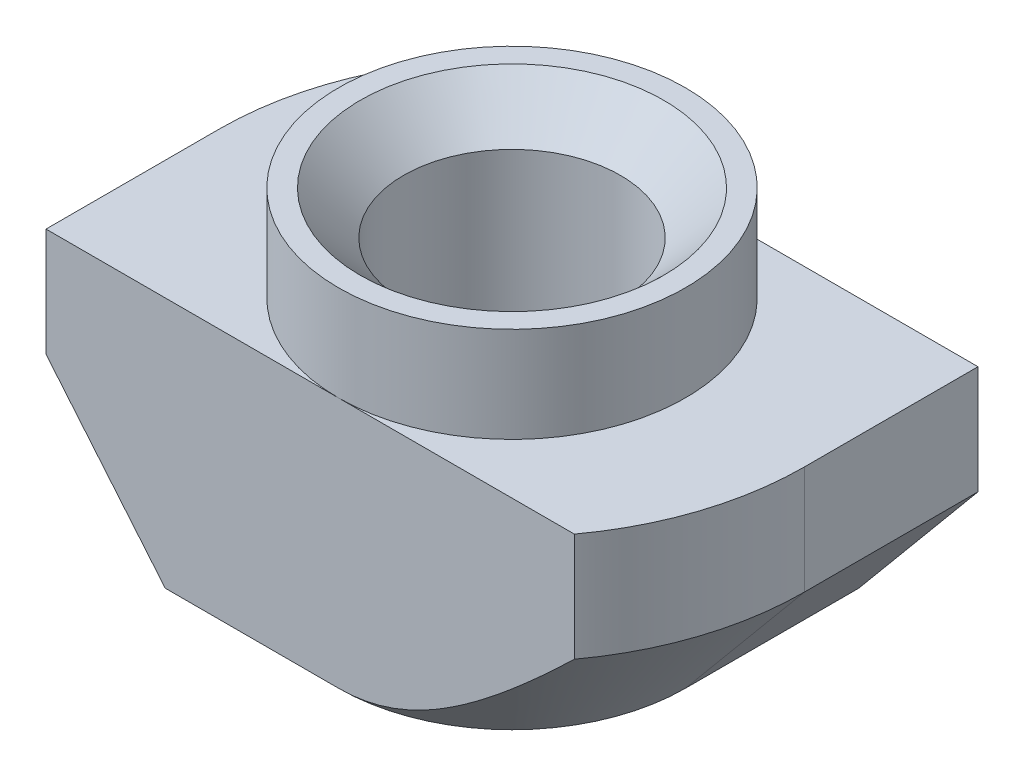
from build123d import *

# Parameters (mm, degrees)
EXTRUDE_1_DEPTH     = 4
SKETCH_4_OUTSIDE_W  = 19.022
SKETCH_4_OUTSIDE_H  = 13.522
SKETCH_4_OUTSIDE_R  = 4
CUT_EXTRUDE_1_DEPTH = 2.2
CUT_EXTRUDE_2_DEPTH = 6.8


with BuildPart() as part:
    # Эскиз1 → Бобышка-Вытянуть1 (new body, symmetric)
    with BuildSketch(Plane.XY):
        Polygon((4, 0), (-4, 0), (-4, -2.2), (-6.75, -2.2), (-6.75, -8), (6.75, -8), (6.75, -2.2), (4, -2.2), align=None)
    extrude(amount=EXTRUDE_1_DEPTH, both=True)

    # Эскиз3 → Отверстие обработанное метчиком M62 (revolve, cut)
    with BuildSketch(Plane(origin=(0, 0, 0), x_dir=(0, 0, 1), z_dir=(1, 0, 0))):
        Polygon((0, 0), (0, 8), (3.5, 8), (2.5, 7), (2.5, 1), (3.5, 0), align=None)
    revolve(axis=Axis((0, 6.35, 0), (0, -1, 0)), mode=Mode.SUBTRACT)

    # Эскиз4 outside → Вырез-Вытянуть1 (cut)
    with BuildSketch(Plane(origin=(0, 0, 0), x_dir=(1, 0, 0), z_dir=(0, 1, 0))):
        Rectangle(SKETCH_4_OUTSIDE_W, SKETCH_4_OUTSIDE_H)
        with Locations(Location((0, 0, 0), (0, 0, 270))):  # turned: the seam where the file's is
            Circle(SKETCH_4_OUTSIDE_R, mode=Mode.SUBTRACT)
    extrude(amount=-CUT_EXTRUDE_1_DEPTH, mode=Mode.SUBTRACT)

    # Эскиз5 → Вырез-Вытянуть2 (cut, through all)
    with BuildSketch(Plane(origin=(0, -2.2, 0), x_dir=(1, 0, 0), z_dir=(0, 1, 0))):
        with BuildLine():
            Line((-6.75, 0), (-6.75, 4))
            Line((-6.75, 4), (-5.437140793, 4))
            ThreePointArc((-5.437140793, 4), (-6.413392252, 2.104970267), (-6.75, 0))
        make_face()
        with BuildLine():
            Line((6.75, 0), (6.75, -4))
            Line((6.75, -4), (5.437140793, -4))
            ThreePointArc((5.437140793, -4), (6.413392252, -2.104970267), (6.75, 0))
        make_face()
    extrude(amount=-CUT_EXTRUDE_2_DEPTH, mode=Mode.SUBTRACT)

    # Вырез-По траектории1: sweep along a path in Эскиз7
    with BuildLine(Plane.XZ.offset(8)) as sweep_1_path:
        Line((0, 6.75), (-6.75, 6.75))
        Line((-6.75, 6.75), (-6.75, 0))
        ThreePointArc((-6.75, 0), (-4.772970773, -4.772970773), (0, -6.75))
        Line((0, -6.75), (6.75, -6.75))
        Line((6.75, -6.75), (6.75, 0))
        ThreePointArc((6.75, 0), (4.772970773, 4.772970773), (0, 6.75))
    # Эскиз6 → Вырез-По траектории1 (sweep, cut)
    with BuildSketch(Plane.XY.offset(4)):
        Polygon((-6.75, -4.7), (-6.75, -8), (-4, -8), align=None)
    sweep(path=sweep_1_path.line, transition=Transition.RIGHT, mode=Mode.SUBTRACT)


solid = part.part
